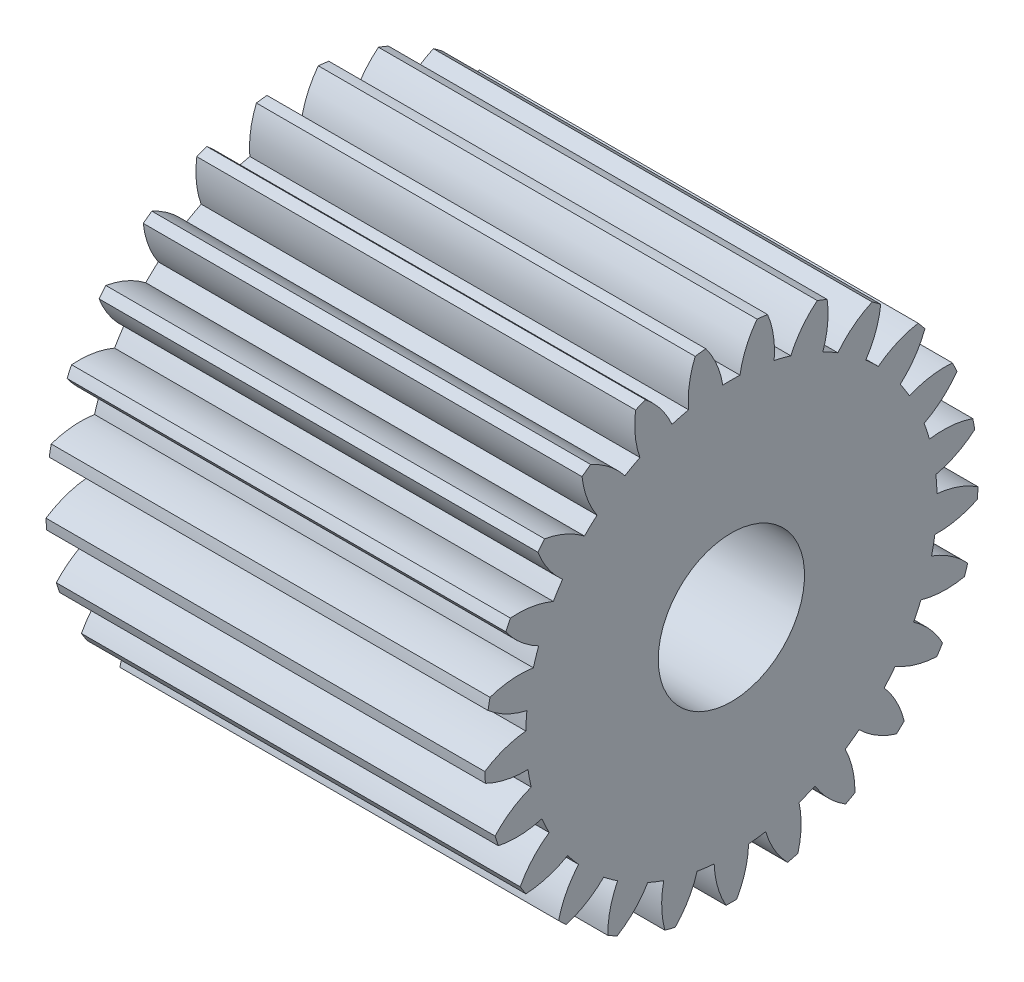
from build123d import *

# Parameters (mm, degrees)
BASPROSKE_W     = 6
BASPROSKE_H     = 3.375
TOOTHCUT_DEPTH  = 8.666893113
TEETHCUTS_COUNT = 25
TEETHCUTS_ANGLE = 345.6
BORSKE_R        = 1
BORE_DEPTH      = 50.0000508


with BuildPart() as part:
    # BasProSke → Base-Revolve (revolve)
    with BuildSketch(Plane(origin=(0, 0, 0), x_dir=(1, 0, 0), z_dir=(0, 1, 0)), mode=Mode.PRIVATE) as base_revolve_sk:
        with Locations((3, 1.6875)):
            Rectangle(BASPROSKE_W, BASPROSKE_H)
    revolve(base_revolve_sk.sketch.rotate(Axis((-10, 0, 0), (1, 0, 0)), 180), axis=Axis((-10, 0, 0), (1, 0, 0)))

    # TooCutSke → ToothCut (cut, through all)
    with BuildSketch(Plane(origin=(0, 0, 0), x_dir=(0, 0, -1), z_dir=(1, 0, 0))):
        with BuildLine():
            ThreePointArc((0.11753566, 2.809042118), (0, 2.8115), (-0.11753566, 2.809042118))
            ThreePointArc((-0.11753566, 2.809042118), (-0.206979317, 3.11062704), (-0.368882924, 3.380332165))
            ThreePointArc((-0.368882924, 3.380332165), (0, 3.4004), (0.368882924, 3.380332165))
            ThreePointArc((0.368882924, 3.380332165), (0.206979317, 3.11062704), (0.11753566, 2.809042118))
        make_face()
    toothcut = extrude(amount=TOOTHCUT_DEPTH, mode=Mode.SUBTRACT)

    # TeethCuts: ToothCut ×25 about axis
    teethcuts_axis = Axis((-10, 0, 0), (1, 0, 0))
    for i in range(1, TEETHCUTS_COUNT):
        add(toothcut.rotate(teethcuts_axis, i * TEETHCUTS_ANGLE / (TEETHCUTS_COUNT - 1)), mode=Mode.SUBTRACT)

    # BorSke → Bore (cut, symmetric)
    with BuildSketch(Plane(origin=(0, 0, 0), x_dir=(0, 0, -1), z_dir=(1, 0, 0))):
        with Locations(Location((0, 0, 0), (0, 0, 180))):
            Circle(BORSKE_R)
    extrude(amount=BORE_DEPTH, both=True, mode=Mode.SUBTRACT)


solid = part.part
